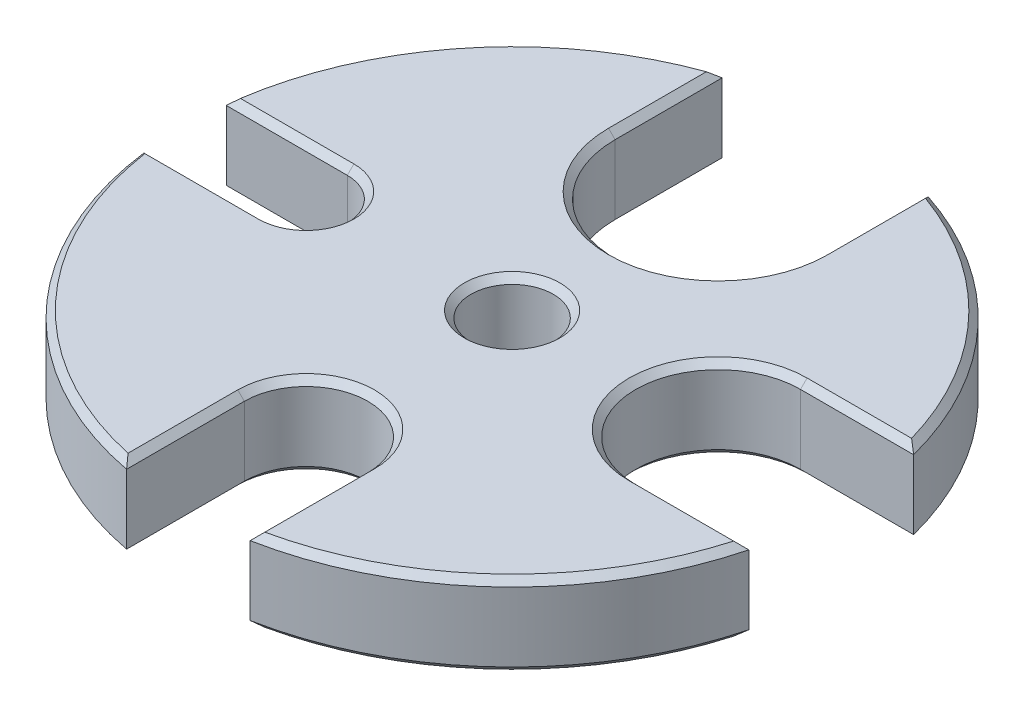
from build123d import *

# Parameters (mm, degrees)
SKETCH1_R           = 0.5
BOSS_EXTRUDE1_DEPTH = 0.5
CHAMFER1_SIZE       = 0.08
CHAMFER2_SIZE       = 0.08


with BuildPart() as part:
    # Sketch1 → Boss-Extrude1 (new body, symmetric)
    with BuildSketch(Plane(origin=(0, 0, 0), x_dir=(1, 0, 0), z_dir=(0, 1, 0))):
        with BuildLine():
            Line((-2.5, 0.5), (-3.968626967, 0.5))
            ThreePointArc((-3.968626967, 0.5), (-3.087146594, 2.543526274), (-1.25, 3.799671038))
            Line((-1.25, 3.799671038), (-1.25, 2.5))
            ThreePointArc((-1.25, 2.5), (0, 1.25), (1.25, 2.5))
            Line((1.25, 2.5), (1.25, 3.799671038))
            ThreePointArc((1.25, 3.799671038), (2.919037354, 2.734816434), (3.872983346, 1))
            Line((3.872983346, 1), (2.5, 1))
            ThreePointArc((2.5, 1), (1.5, 0), (2.5, -1))
            Line((2.5, -1), (3.872983346, -1))
            ThreePointArc((3.872983346, -1), (2.736391702, -2.917560702), (0.75, -3.929058411))
            Line((0.75, -3.929058411), (0.75, -2.5))
            ThreePointArc((0.75, -2.5), (0, -1.75), (-0.75, -2.5))
            Line((-0.75, -2.5), (-0.75, -3.929058411))
            ThreePointArc((-0.75, -3.929058411), (-2.916499702, -2.73752251), (-3.968626967, -0.5))
            Line((-3.968626967, -0.5), (-2.5, -0.5))
            ThreePointArc((-2.5, -0.5), (-2, 0), (-2.5, 0.5))
        make_face()
        Circle(SKETCH1_R, mode=Mode.SUBTRACT)
    extrude(amount=BOSS_EXTRUDE1_DEPTH, both=True)

    # Chamfer1
    chamfer1_edges = [part.edges().sort_by_distance(p)[0] for p in [
        (-2, 0.5, 0),
        (-3.234313483, 0.5, 0.5),
        (-2.916499702, 0.5, 2.73752251),
        (-0.75, 0.5, 3.214529206),
        (0, 0.5, 1.75),
        (0.75, 0.5, 3.214529206),
        (2.736391702, 0.5, 2.917560702),
        (-0.5, 0.5, 0),
        (3.186491673, 0.5, 1),
        (1.5, 0.5, 0),
        (3.186491673, 0.5, -1),
        (-3.087146594, 0.5, -2.543526274),
        (2.919037354, 0.5, -2.734816434),
        (1.25, 0.5, -3.149835519),
        (0, 0.5, -1.25),
        (-1.25, 0.5, -3.149835519),
        (-3.234313483, 0.5, -0.5),
    ]]
    chamfer(chamfer1_edges, length=CHAMFER1_SIZE)

    # Chamfer2
    chamfer2_edges = [part.edges().sort_by_distance(p)[0] for p in [
        (-1.25, -0.5, -3.149835519),
        (0, -0.5, -1.25),
        (1.25, -0.5, -3.149835519),
        (2.919037354, -0.5, -2.734816434),
        (3.186491673, -0.5, -1),
        (1.5, -0.5, 0),
        (3.186491673, -0.5, 1),
        (2.736391702, -0.5, 2.917560702),
        (0.75, -0.5, 3.214529206),
        (0, -0.5, 1.75),
        (-0.75, -0.5, 3.214529206),
        (-2.916499702, -0.5, 2.73752251),
        (-3.234313483, -0.5, 0.5),
        (-2, -0.5, 0),
        (-3.234313483, -0.5, -0.5),
        (-3.087146594, -0.5, -2.543526274),
        (-0.5, -0.5, 0),
    ]]
    chamfer(chamfer2_edges, length=CHAMFER2_SIZE)


solid = part.part
